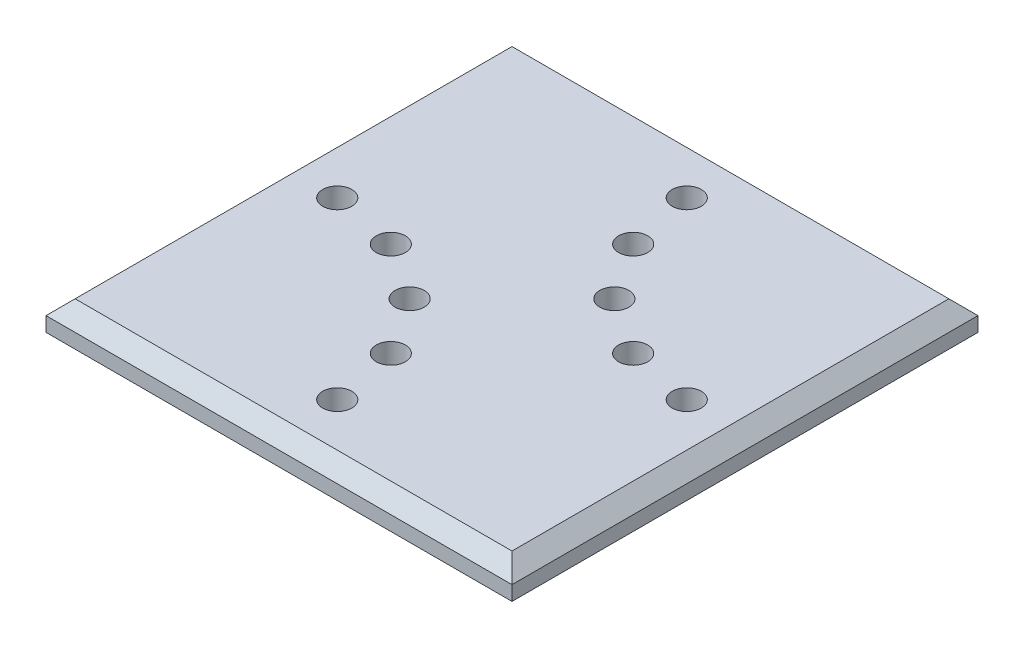
from build123d import *

# Parameters (mm, degrees)
SKETCH1_W               = 101.6
SKETCH1_H               = 101.6
BOSS_EXTRUDE1_DEPTH     = 9.525
SKETCH2_W               = 101.6
SKETCH2_H               = 101.6
SKETCH2_W_2             = 94.996
SKETCH2_H_2             = 94.996
CUT_EXTRUDE1_DEPTH      = 3.175
CHAMFER1_SIZE           = 3.175
SKETCH11_R              = 3.175
CUT_EXTRUDE4_DEPTH      = 1
CUT_EXTRUDE4_DEPTH_BACK = 10.525


with BuildPart() as part:
    # Sketch1 → Boss-Extrude1 (new body)
    with BuildSketch(Plane(origin=(0, 0, 0), x_dir=(1, 0, 0), z_dir=(0, 1, 0))):
        Rectangle(SKETCH1_W, SKETCH1_H)
    extrude(amount=BOSS_EXTRUDE1_DEPTH)

    # Sketch2 → Cut-Extrude1 (cut)
    with BuildSketch(Plane.XZ):
        Rectangle(SKETCH2_W, SKETCH2_H)
        Rectangle(SKETCH2_W_2, SKETCH2_H_2, mode=Mode.SUBTRACT)
    extrude(amount=-CUT_EXTRUDE1_DEPTH, mode=Mode.SUBTRACT)

    # Chamfer1
    chamfer1_edges = [part.edges().sort_by_distance(p)[0] for p in [
        (-50.8, 9.525, 0),
        (0, 9.525, 50.8),
        (50.8, 9.525, 0),
        (0, 9.525, -50.8),
    ]]
    chamfer(chamfer1_edges, length=CHAMFER1_SIZE)

    # Sketch11 → Cut-Extrude4 (cut, two sides)
    with BuildSketch(Plane(origin=(0, 9.525, 0), x_dir=(1, 0, 0), z_dir=(0, 1, 0))) as cut_extrude4_sk:
        with Locations((-38.1, 0)):
            Circle(SKETCH11_R)
        with Locations((0, -38.1)):
            Circle(SKETCH11_R)
        with Locations((-11.159231637, -11.159231637)):
            Circle(SKETCH11_R)
        with Locations((-23.519761227, -2.900189811)):
            Circle(SKETCH11_R)
        with Locations((-2.900189811, -23.519761227)):
            Circle(SKETCH11_R)
        with Locations((38.1, 0)):
            Circle(SKETCH11_R)
        with Locations((23.519761227, 2.900189811)):
            Circle(SKETCH11_R)
        with Locations((11.159231637, 11.159231637)):
            Circle(SKETCH11_R)
        with Locations((2.900189811, 23.519761227)):
            Circle(SKETCH11_R)
        with Locations((0, 38.1)):
            Circle(SKETCH11_R)
    extrude(amount=CUT_EXTRUDE4_DEPTH, mode=Mode.SUBTRACT)
    extrude(cut_extrude4_sk.sketch, amount=-CUT_EXTRUDE4_DEPTH_BACK, mode=Mode.SUBTRACT)


solid = part.part
